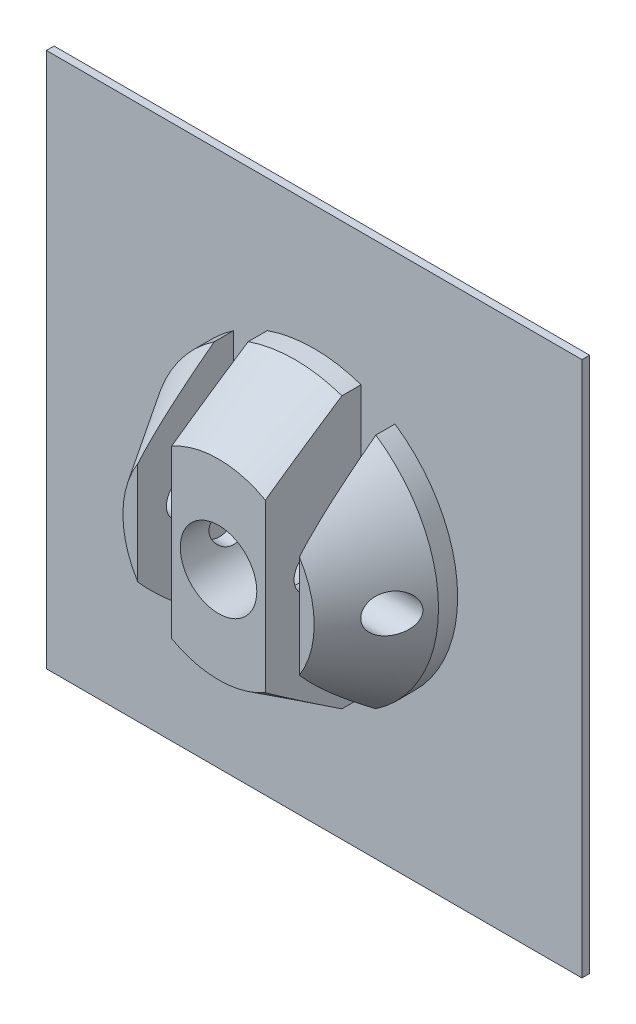
from build123d import *

# Parameters (mm, degrees)
CROQUIS1_W              = 56
CROQUIS1_H              = 56
CROQUIS1_R              = 2
SALIENTE_EXTRUIR2_DEPTH = 0.8
CROQUIS4_R              = 4
CROQUIS4_W              = 3.55
CROQUIS4_H              = 40
CORTAR_EXTRUIR1_DEPTH   = 10
CORTAR_EXTRUIR2_START   = -42.374993
CROQUIS7_R              = 2
CORTAR_EXTRUIR2_DEPTH   = 28.749989
SALIENTE_EXTRUIR4_DEPTH = 10


with BuildPart() as part:
    # Croquis1 → Saliente-Extruir2 (new body)
    with BuildSketch(Plane.XY):
        Rectangle(CROQUIS1_W, CROQUIS1_H)
        Circle(CROQUIS1_R, mode=Mode.SUBTRACT)
    extrude(amount=SALIENTE_EXTRUIR2_DEPTH)

    # Croquis2 → Revolución1 (revolve)
    with BuildSketch(Plane(origin=(0, 0, 0), x_dir=(0, 0, -1), z_dir=(1, 0, 0))):
        Polygon((-0.8, 0), (-10.8, 0), (-10.8, 10), (-2.8, 15), (-0.8, 15), align=None)
    revolve(axis=Axis((0, 0, 0.8), (0, 0, 1)))

    # Croquis4 → Cortar-Extruir1 (cut)
    with BuildSketch(Plane.XY.offset(10.8)):
        Circle(CROQUIS4_R)
        with Locations((-6.675, 0)):
            Rectangle(CROQUIS4_W, CROQUIS4_H)
        with Locations((6.675, 0)):
            Rectangle(CROQUIS4_W, CROQUIS4_H)
    extrude(amount=-CORTAR_EXTRUIR1_DEPTH, mode=Mode.SUBTRACT)

    # Croquis7 → Cortar-Extruir2 (cut)
    with BuildSketch(Plane.ZY.offset(28).offset(CORTAR_EXTRUIR2_START)):
        with Locations((5.8, 0)):
            Circle(CROQUIS7_R)
    extrude(amount=CORTAR_EXTRUIR2_DEPTH, mode=Mode.SUBTRACT)

    # Croquis3 → Saliente-Extruir4 (add)
    with BuildSketch(Plane.XY.offset(0.8)):
        with BuildLine():
            Line((23, -28), (28, -28))
            Line((28, -28), (28, -23))
            ThreePointArc((28, -23), (31.535533906, -31.535533906), (23, -28))
        make_face()
    extrude(amount=SALIENTE_EXTRUIR4_DEPTH)


with BuildPart() as saliente_extruir4_kept_piece:
    # of the separate pieces the step leaves, the one the design keeps (saliente_extruir4_pieces_kept)
    add(part.part.solids().sort_by_distance((28, -28, 0))[0])


solid = saliente_extruir4_kept_piece.part
